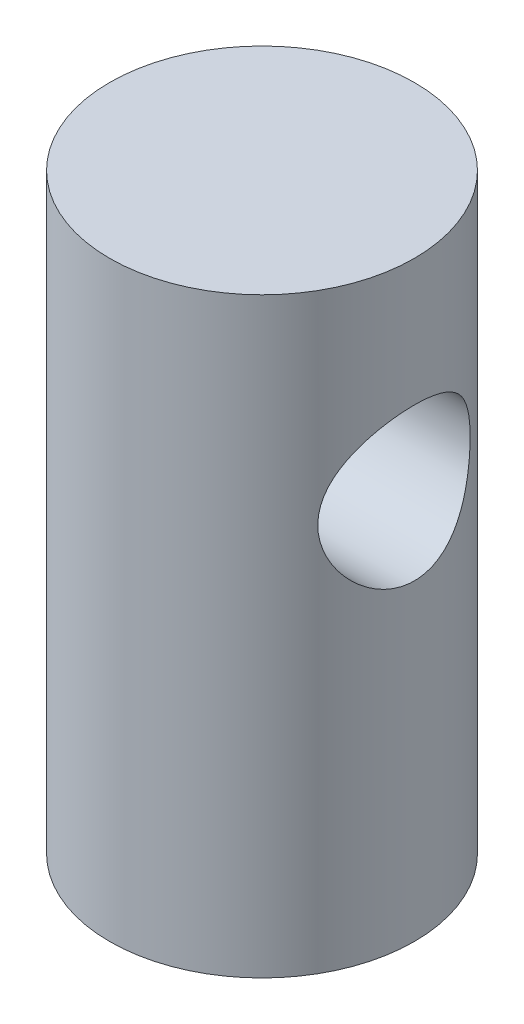
from build123d import *

# Parameters (mm, degrees)
SKETCH1_R           = 3.81
BOSS_EXTRUDE1_DEPTH = 14.7955
SKETCH2_R           = 1.905
CUT_EXTRUDE1_DEPTH  = 8.62


with BuildPart() as part:
    # Sketch1 → Boss-Extrude1 (new body)
    with BuildSketch(Plane(origin=(0, 0, 0), x_dir=(1, 0, 0), z_dir=(0, 1, 0))):
        Circle(SKETCH1_R)
    extrude(amount=BOSS_EXTRUDE1_DEPTH)

    # Sketch2 → Cut-Extrude1 (cut, through all)
    with BuildSketch(Plane(origin=(3.81, 0, 0), x_dir=(0, 0, -1), z_dir=(1, 0, 0))):
        with Locations((0, 9.7155)):
            Circle(SKETCH2_R)
    extrude(amount=-CUT_EXTRUDE1_DEPTH, mode=Mode.SUBTRACT)


solid = part.part
